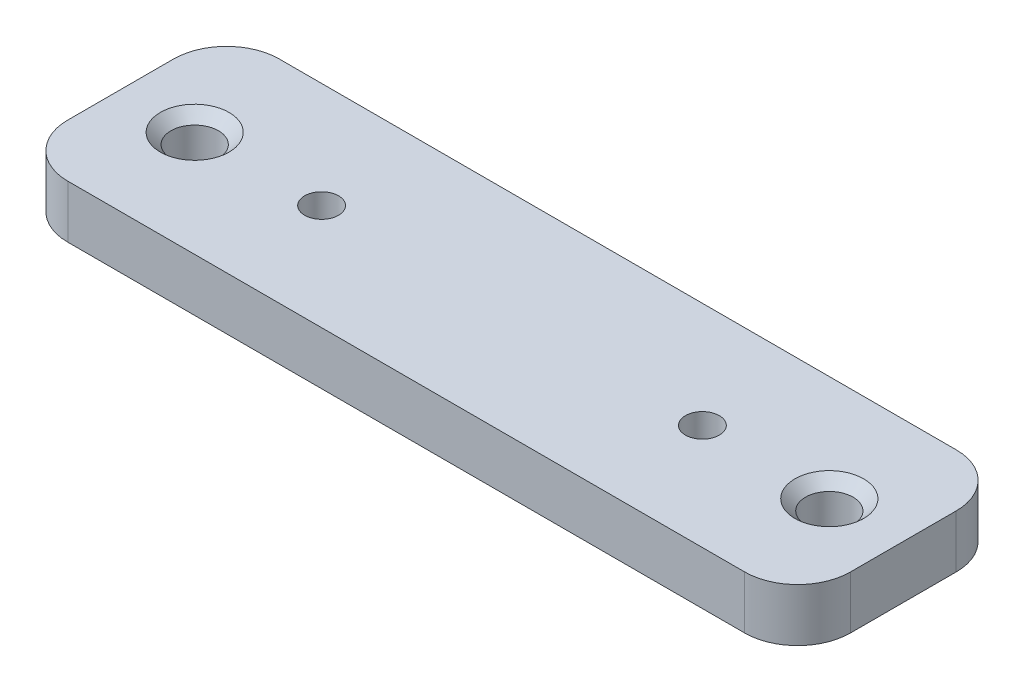
from build123d import *

# Parameters (mm, degrees)
SKETCH_1_W      = 74
SKETCH_1_H      = 20
SKETCH_1_R      = 1.6
SKETCH_1_R_2    = 2.25
EXTRUDE_1_DEPTH = 5
FILLET_2_R      = 5
CHAMFER_1_SIZE  = 1
CHAMFER_2_SIZE  = 1


with BuildPart() as part:
    # Эскиз1 → Бобышка-Вытянуть1 (new body)
    with BuildSketch(Plane(origin=(0, 0, 0), x_dir=(1, 0, 0), z_dir=(0, 1, 0))):
        with Locations((37, 10)):
            Rectangle(SKETCH_1_W, SKETCH_1_H)
        with Locations((19, 10)):
            Circle(SKETCH_1_R, mode=Mode.SUBTRACT)
        with Locations((55, 10)):
            Circle(SKETCH_1_R, mode=Mode.SUBTRACT)
        with Locations((7, 10)):
            Circle(SKETCH_1_R_2, mode=Mode.SUBTRACT)
        with Locations((67, 10)):
            Circle(SKETCH_1_R_2, mode=Mode.SUBTRACT)
    extrude(amount=EXTRUDE_1_DEPTH)

    # Скругление2
    fillet_2_edges = [part.edges().sort_by_distance(p)[0] for p in [
        (0, 2.5, -20),
        (74, 2.5, -20),
        (74, 2.5, 0),
        (0, 2.5, 0),
    ]]
    fillet(fillet_2_edges, radius=FILLET_2_R)

    # Фаска1
    chamfer_1_edges = [part.edges().sort_by_distance(p)[0] for p in [
        (4.75, 5, -10),
        (64.75, 5, -10),
    ]]
    chamfer(chamfer_1_edges, length=CHAMFER_1_SIZE)

    # Фаска2
    chamfer_2_edges = [part.edges().sort_by_distance(p)[0] for p in [
        (17.4, 0, -10),
        (53.4, 0, -10),
    ]]
    chamfer(chamfer_2_edges, length=CHAMFER_2_SIZE)


solid = part.part
